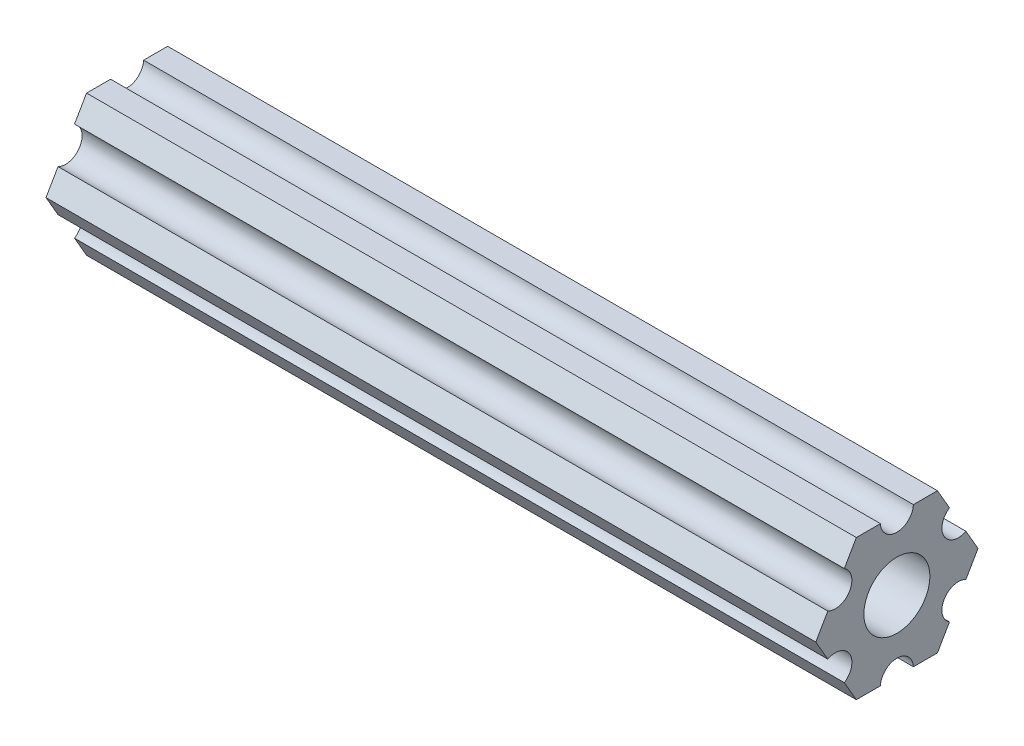
from build123d import *

# Parameters (mm, degrees)
BOSS_EXTRUDE1_START = -34.064
SKETCH2_R           = 2.921
BOSS_EXTRUDE1_DEPTH = 68.128


with BuildPart() as part:
    # Sketch2 → Boss-Extrude1 (new body)
    with BuildSketch(Plane(origin=(0, 0, 0), x_dir=(0, 0, -1), z_dir=(1, 0, 0)).offset(BOSS_EXTRUDE1_START)):
        with BuildLine():
            Line((-1.82176, 39.714214029), (-3.950444551, 39.714214029))
            ThreePointArc((-3.950444551, 39.714214029), (-5.410944551, 38.323564029), (-6.871444551, 39.714214029))
            Line((-6.871444551, 39.714214029), (-9.000129101, 39.714214029))
            Line((-9.000129101, 39.714214029), (-10.064471377, 37.870719131))
            ThreePointArc((-10.064471377, 37.870719131), (-9.590383149, 35.910564029), (-11.524971377, 35.341058926))
            Line((-11.524971377, 35.341058926), (-12.589313652, 33.497564029))
            Line((-12.589313652, 33.497564029), (-11.524971377, 31.654069131))
            ThreePointArc((-11.524971377, 31.654069131), (-9.590383149, 31.084564029), (-10.064471377, 29.124408926))
            Line((-10.064471377, 29.124408926), (-9.000129101, 27.280914029))
            Line((-9.000129101, 27.280914029), (-6.871444551, 27.280914029))
            ThreePointArc((-6.871444551, 27.280914029), (-5.410944551, 28.671564029), (-3.950444551, 27.280914029))
            Line((-3.950444551, 27.280914029), (-1.82176, 27.280914029))
            Line((-1.82176, 27.280914029), (-0.757417724, 29.124408926))
            ThreePointArc((-0.757417724, 29.124408926), (-1.231505952, 31.084564029), (0.703082276, 31.654069131))
            Line((0.703082276, 31.654069131), (1.767424551, 33.497564029))
            Line((1.767424551, 33.497564029), (0.703082276, 35.341058926))
            ThreePointArc((0.703082276, 35.341058926), (-1.231505952, 35.910564029), (-0.757417724, 37.870719131))
            Line((-0.757417724, 37.870719131), (-1.82176, 39.714214029))
        make_face()
        with Locations((-5.410944551, 33.497564029)):
            Circle(SKETCH2_R, mode=Mode.SUBTRACT)
    extrude(amount=BOSS_EXTRUDE1_DEPTH)


solid = part.part
